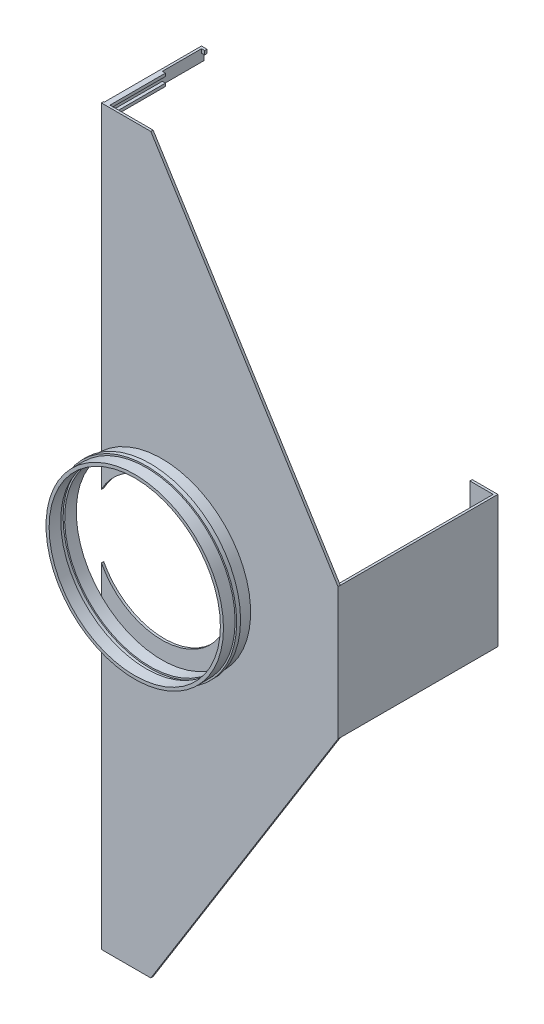
from build123d import *

# Parameters (mm, degrees)
SKETCH1_W       = 305
SKETCH1_H       = 945
EXTRUDE1_DEPTH  = 3
SKETCH2_R       = 114.37
SKETCH2_R_2     = 110.37
EXTRUDE2_DEPTH  = 15
SKETCH3_W       = 3
SKETCH3_H       = 15
EXTRUDE3_DEPTH  = 125
SKETCH4_W       = 3
SKETCH4_H       = 5
SKETCH4_H_2     = 6
SKETCH4_W_2     = 74.4375
SKETCH4_H_3     = 3.826546867
SKETCH4_H_4     = 3.798552334
SKETCH4_W_3     = 55.3875
SKETCH4_H_5     = 4.7625
SKETCH4_H_6     = 3.8875
EXTRUDE4_DEPTH  = 4
SKETCH5_W       = 3
SKETCH5_H       = 170
EXTRUDE5_DEPTH  = 203
SKETCH6_W       = 3
SKETCH6_H       = 170
EXTRUDE6_DEPTH  = 30
EXTRUDE7_DEPTH  = 19
SKETCH13_R      = 88.098729295
EXTRUDE10_DEPTH = 207
SKETCH22_R      = 116.4
SKETCH22_R_2    = 112.37
EXTRUDE17_DEPTH = 5
SKETCH23_R      = 114.37
SKETCH23_R_2    = 110.37
EXTRUDE18_DEPTH = 15


with BuildPart() as part:
    # Sketch1 → Extrude1 (new body)
    with BuildSketch(Plane.XY):
        with Locations((152.5, 472.5)):
            Rectangle(SKETCH1_W, SKETCH1_H)
    extrude(amount=EXTRUDE1_DEPTH)

    # Sketch2 → Extrude2 (add)
    with BuildSketch(Plane.XY.offset(3)):
        with Locations((78, 472.5)):
            Circle(SKETCH2_R)
        with Locations((78, 472.5)):
            Circle(SKETCH2_R_2, mode=Mode.SUBTRACT)
    extrude(amount=EXTRUDE2_DEPTH)

    # Sketch3 → Extrude3 (add)
    with BuildSketch(Plane(origin=(0, 0, 0), x_dir=(-1, 0, 0), z_dir=(0, 0, -1))):
        with Locations((-2.5, 937.5)):
            Rectangle(SKETCH3_W, SKETCH3_H)
        with Locations((-2.5, 7.5)):
            Rectangle(SKETCH3_W, SKETCH3_H)
    extrude(amount=EXTRUDE3_DEPTH)

    # Sketch4 → Extrude4 (add)
    with BuildSketch(Plane(origin=(4, 0, 0), x_dir=(0, 0, -1), z_dir=(1, 0, 0))):
        with Locations((123.5, 942.5)):
            Rectangle(SKETCH4_W, SKETCH4_H)
        with Locations((123.5, 3)):
            Rectangle(SKETCH4_W, SKETCH4_H_2)
        with Locations((34.21875, 943.086726567)):
            Rectangle(SKETCH4_W_2, SKETCH4_H_3)
        with Locations((34.21875, 931.899276167)):
            Rectangle(SKETCH4_W_2, SKETCH4_H_4)
        with Locations((24.69375, 2.38125)):
            Rectangle(SKETCH4_W_3, SKETCH4_H_5)
        with Locations((24.69375, 13.05625)):
            Rectangle(SKETCH4_W_3, SKETCH4_H_6)
    extrude(amount=EXTRUDE4_DEPTH)

    # Sketch5 → Extrude5 (add)
    with BuildSketch(Plane(origin=(0, 0, 0), x_dir=(-1, 0, 0), z_dir=(0, 0, -1))):
        with Locations((-303.5, 472.5)):
            Rectangle(SKETCH5_W, SKETCH5_H)
    extrude(amount=EXTRUDE5_DEPTH)

    # Sketch6 → Extrude6 (add)
    with BuildSketch(Plane.ZY.offset(-302)):
        with Locations((-201.5, 472.5)):
            Rectangle(SKETCH6_W, SKETCH6_H)
    extrude(amount=EXTRUDE6_DEPTH)

    # Sketch7 → Extrude7 (cut, through all)
    with BuildSketch(Plane(origin=(0, 0, 0), x_dir=(-1, 0, 0), z_dir=(0, 0, -1))):
        Polygon((-305, 557.5), (-63.714944106, 945), (-305, 945), align=None)
        Polygon((-305, 387.5), (-63.714944106, 0), (-305, 0), align=None)
    extrude(amount=-EXTRUDE7_DEPTH, mode=Mode.SUBTRACT)

    # Sketch13 → Extrude10 (cut, through all)
    with BuildSketch(Plane.XY.offset(3)):
        with Locations((78, 472.5)):
            Circle(SKETCH13_R)
    extrude(amount=-EXTRUDE10_DEPTH, mode=Mode.SUBTRACT)

    # Sketch22 → Extrude17 (add)
    with BuildSketch(Plane.XY.offset(18)):
        with Locations((78, 472.5)):
            Circle(SKETCH22_R)
        with Locations((78, 472.5)):
            Circle(SKETCH22_R_2, mode=Mode.SUBTRACT)
    extrude(amount=EXTRUDE17_DEPTH)

    # Sketch23 → Extrude18 (add)
    with BuildSketch(Plane.XY.offset(23)):
        with Locations((78, 472.5)):
            Circle(SKETCH23_R)
        with Locations((78, 472.5)):
            Circle(SKETCH23_R_2, mode=Mode.SUBTRACT)
    extrude(amount=EXTRUDE18_DEPTH)


solid = part.part
